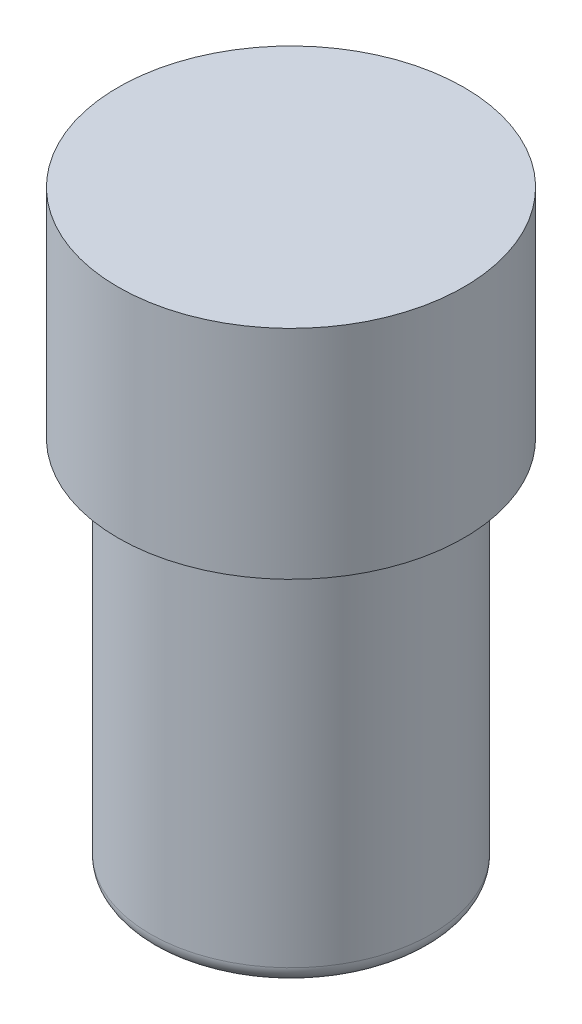
from build123d import *

# Parameters (mm, degrees)
SKETCH1_R           = 5.0535
BOSS_EXTRUDE1_DEPTH = 6.35
SKETCH1_3_R         = 4.1047
BOSS_EXTRUDE2_DEPTH = 11
FILLET2_R           = 0.5


with BuildPart() as part:
    # Sketch1 → Boss-Extrude1 (new body)
    with BuildSketch(Plane(origin=(0, 0, 0), x_dir=(1, 0, 0), z_dir=(0, 1, 0))):
        Circle(SKETCH1_R)
    extrude(amount=BOSS_EXTRUDE1_DEPTH)

    # Sketch1_3 → Boss-Extrude2 (add)
    with BuildSketch(Plane(origin=(0, 0, 0), x_dir=(1, 0, 0), z_dir=(0, 1, 0))):
        Circle(SKETCH1_3_R)
    extrude(amount=-BOSS_EXTRUDE2_DEPTH)

    # Fillet2
    fillet2_edges = [part.edges().sort_by_distance(p)[0] for p in [
        (-4.1047, 0, 0),
        (-4.1047, -11, 0),
    ]]
    fillet(fillet2_edges, radius=FILLET2_R)


solid = part.part
